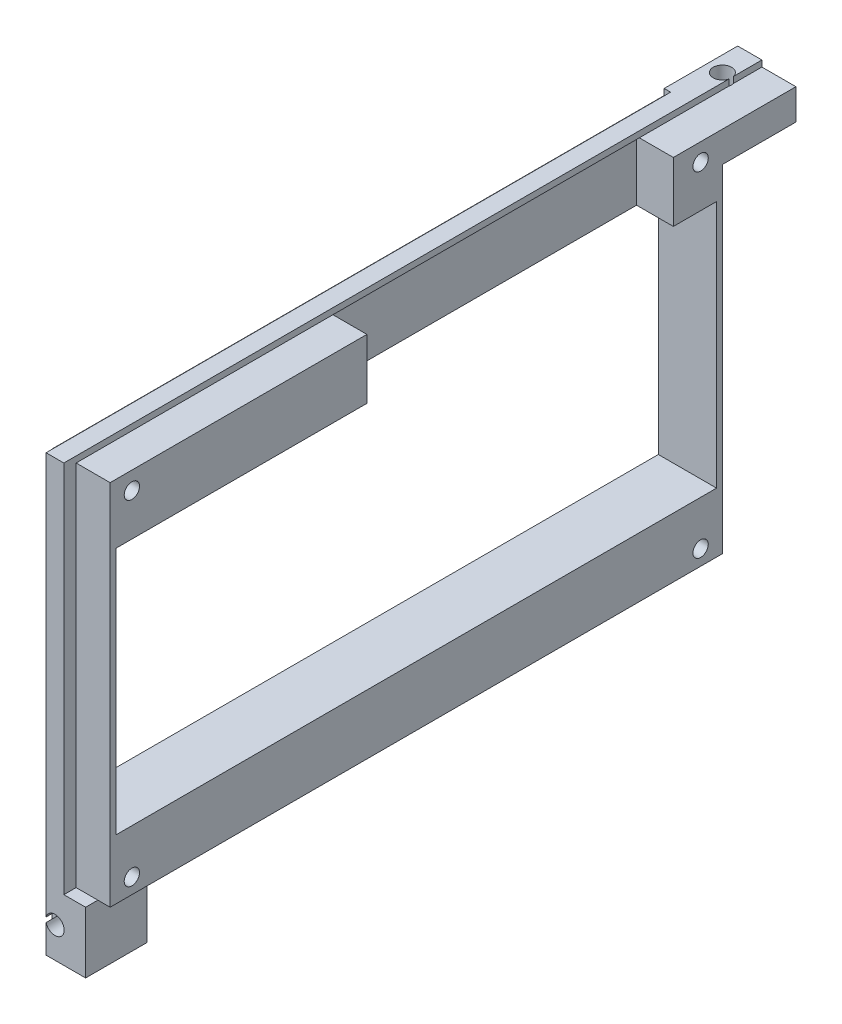
from build123d import *

# Parameters (mm, degrees)
ESQUISSE1_W             = 12
ESQUISSE1_H             = 60
MAIN_DEPTH              = 49.95
ESQUISSE2_R             = 1.25
HOLESFIXFORLCD_DEPTH    = 13
SKETCH1_W               = 98
SKETCH1_H               = 40.5
LCDWINDOWHOLE_DEPTH     = 13
SKETCH6_W               = 2.9
SKETCH6_H               = 2
MAKERBEAMRAIL_DEPTH     = 60
SKETCH7_W               = 50
SKETCH7_H               = 9.75
LCDPINSHOLES_DEPTH      = 6
SKETCH8_W               = 8
SKETCH8_H               = 40.5
REINFORCEMENT_DEPTH     = 2.5
REINFORCEMENT_2_DEPTH   = 2.5
SKETCH12_W              = 2.5
SKETCH12_H              = 69
WINDOWPLASTICHOLE_DEPTH = 104.9
SKETCH13_W              = 2.9
SKETCH13_H              = 1
MAKERBEAMRAILUP_DEPTH   = 103.9
BOSS_EXTRUDE2_DEPTH     = 12
SKETCH15_R              = 1.5
CUT_EXTRUDE4_DEPTH      = 7
BOSS_EXTRUDE3_DEPTH     = 10
SKETCH17_R              = 1.5
CUT_EXTRUDE5_DEPTH      = 114.9


with BuildPart() as part:
    # Esquisse1 → Main (new body, symmetric)
    with BuildSketch(Plane.XY):
        with Locations((6, 30)):
            Rectangle(ESQUISSE1_W, ESQUISSE1_H)
    extrude(amount=MAIN_DEPTH, both=True)

    # Esquisse2 → HolesFixForLCD (cut, through all)
    with BuildSketch(Plane(origin=(12, 0, 0), x_dir=(0, 0, -1), z_dir=(1, 0, 0))):
        with Locations((46.4, 2.5)):
            Circle(ESQUISSE2_R)
        with Locations((-46.4, 2.5)):
            Circle(ESQUISSE2_R)
        with Locations((46.4, 57.1)):
            Circle(ESQUISSE2_R)
        with Locations((-46.4, 57.1)):
            Circle(ESQUISSE2_R)
    extrude(amount=-HOLESFIXFORLCD_DEPTH, mode=Mode.SUBTRACT)

    # Sketch1 → LCDWindowHole (cut, through all)
    with BuildSketch(Plane(origin=(12, 0, 0), x_dir=(0, 0, -1), z_dir=(1, 0, 0))):
        with Locations((0, 30)):
            Rectangle(SKETCH1_W, SKETCH1_H)
    extrude(amount=-LCDWINDOWHOLE_DEPTH, mode=Mode.SUBTRACT)

    # Sketch6 → MakerBeamRail (add)
    with BuildSketch(Plane(origin=(0, 60, 0), x_dir=(1, 0, 0), z_dir=(0, 1, 0))):
        with Locations((5, 50.95)):
            Rectangle(SKETCH6_W, SKETCH6_H)
        with Locations((5, -50.95)):
            Rectangle(SKETCH6_W, SKETCH6_H)
    extrude(amount=-MAKERBEAMRAIL_DEPTH)

    # Sketch7 → LCDPinsHoles (cut)
    with BuildSketch(Plane(origin=(12, 0, 0), x_dir=(0, 0, -1), z_dir=(1, 0, 0))):
        with Locations((16.95, 55.125)):
            Rectangle(SKETCH7_W, SKETCH7_H)
    extrude(amount=-LCDPINSHOLES_DEPTH, mode=Mode.SUBTRACT)


with BuildPart() as body_2:
    # Sketch8 → Reinforcement (new body)
    with BuildSketch(Plane.ZY):
        with Locations((-45, 30)):
            Rectangle(SKETCH8_W, SKETCH8_H)
    extrude(amount=-REINFORCEMENT_DEPTH)


with BuildPart() as body_3:
    # Sketch8 → Reinforcement 2 (new body)
    with BuildSketch(Plane.ZY):
        with Locations((45, 30)):
            Rectangle(SKETCH8_W, SKETCH8_H)
    extrude(amount=-REINFORCEMENT_2_DEPTH)


with BuildPart() as windowplastichole_tool:
    # Sketch12 → WindowPlasticHole (new body, through all)
    with BuildSketch(Plane.XY.offset(51.95)):
        with Locations((1.25, 34.5)):
            Rectangle(SKETCH12_W, SKETCH12_H)
    extrude(amount=-WINDOWPLASTICHOLE_DEPTH)


with BuildPart() as part_1:
    add(part.part)

    # WindowPlasticHole: cut by windowplastichole_tool
    add(windowplastichole_tool.part, mode=Mode.SUBTRACT)

    # Sketch13 → MakerBeamRailUp (add)
    with BuildSketch(Plane.XY.offset(51.95)):
        with Locations((5, 60.5)):
            Rectangle(SKETCH13_W, SKETCH13_H)
    extrude(amount=-MAKERBEAMRAILUP_DEPTH)

    # Sketch14 → Boss-Extrude2 (add)
    with BuildSketch(Plane(origin=(0, 0, -49.95), x_dir=(-1, 0, 0), z_dir=(0, 0, -1))):
        Polygon((-12, 60), (-6.45, 60), (-6.45, 61), (-2.5, 61), (-2.5, 55), (-12, 55), align=None)
    extrude(amount=BOSS_EXTRUDE2_DEPTH)

    # Sketch15 → Cut-Extrude4 (cut, through all)
    with BuildSketch(Plane.XZ.offset(-55)):
        with Locations((5, -56.95)):
            Circle(SKETCH15_R)
    extrude(amount=-CUT_EXTRUDE4_DEPTH, mode=Mode.SUBTRACT)

    # Sketch16 → Boss-Extrude3 (add)
    with BuildSketch(Plane(origin=(0, 0, 0), x_dir=(-1, 0, 0), z_dir=(0, -1, 0))):
        Polygon((-2.5, -49.95), (-3.55, -49.95), (-3.55, -51.95), (-10, -51.95), (-10, -41.95), (-2.5, -41.95), align=None)
    extrude(amount=BOSS_EXTRUDE3_DEPTH)

    # Sketch17 → Cut-Extrude5 (cut, through all)
    with BuildSketch(Plane.XY.offset(51.95)):
        with Locations((5, -5)):
            Circle(SKETCH17_R)
    extrude(amount=-CUT_EXTRUDE5_DEPTH, mode=Mode.SUBTRACT)


with BuildPart() as body_2_1:
    add(body_2.part)

    # WindowPlasticHole: cut by windowplastichole_tool
    add(windowplastichole_tool.part, mode=Mode.SUBTRACT)


with BuildPart() as body_3_1:
    add(body_3.part)

    # WindowPlasticHole: cut by windowplastichole_tool
    add(windowplastichole_tool.part, mode=Mode.SUBTRACT)


solid = part_1.part
